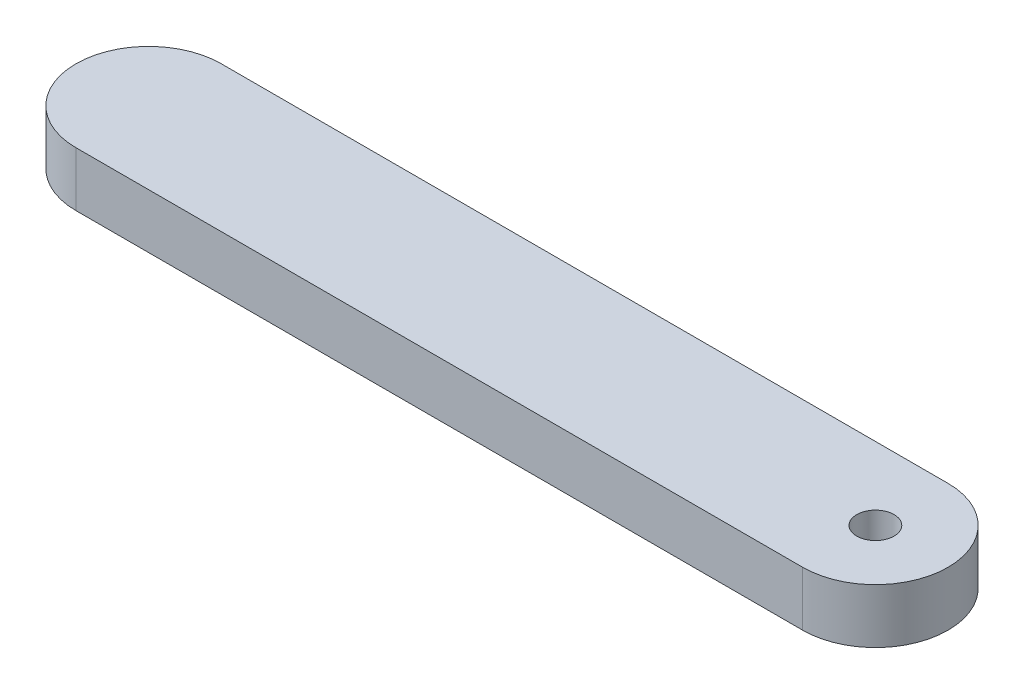
from build123d import *

# Parameters (mm, degrees)
BOSS_EXTRUDE2_DEPTH   = 4.7625
F_4_CLEARANCE_HOLE1_D = 3.2639


with BuildPart() as part:
    # Sketch1 → Boss-Extrude2 (new body)
    with BuildSketch(Plane(origin=(0, 0, 0), x_dir=(1, 0, 0), z_dir=(0, 1, 0))):
        with BuildLine():
            Line((-63.5, 6.35), (0, 6.35))
            ThreePointArc((0, 6.35), (6.35, 0), (0, -6.35))
            Line((0, -6.35), (-63.5, -6.35))
            ThreePointArc((-63.5, -6.35), (-69.85, 0), (-63.5, 6.35))
        make_face()
    extrude(amount=BOSS_EXTRUDE2_DEPTH)

    # #4 Clearance Hole1 (through all)
    with Locations(Plane(origin=(0, 4.7625, 0), x_dir=(1, 0, 0), z_dir=(0, 1, 0))):
        with Locations((0, 0)):
            Hole(F_4_CLEARANCE_HOLE1_D / 2)


solid = part.part
